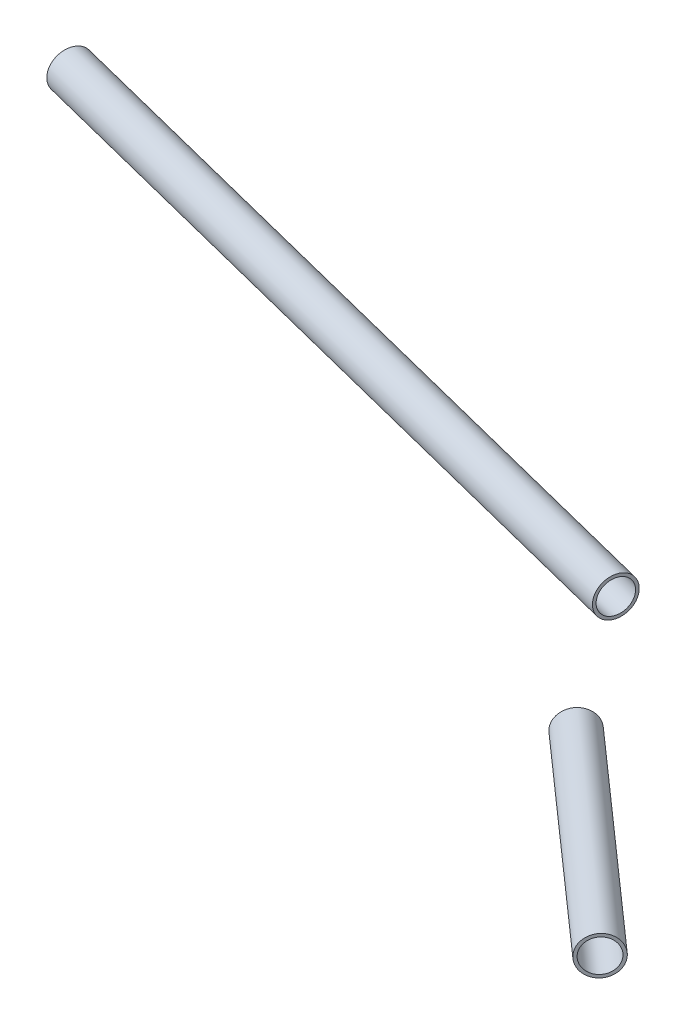
from build123d import *

# Parameters (mm, degrees)
SZKIC1_R                    = 6.349999996
DODANIE_WYCI_GNI_CIE1_DEPTH = 91.164431394
SZKIC2_R                    = 6.349999998
DODANIE_WYCI_GNI_CIE2_DEPTH = 247.228842592
SKORUPA1_T                  = -1
SKORUPA2_T                  = -1


with BuildPart() as part:
    # Szkic1 → Dodanie-wyciągnięcie1 (new body)
    with BuildSketch(Plane(origin=(100.119816365, 0, 88.569559312), x_dir=(-0.6625823992959091, 0, 0.7489890280526655), z_dir=(-0.7489890280526655, 0, -0.6625823992959091))):
        with Locations((423.248159606, 467.999999999)):
            Circle(SZKIC1_R)
    extrude(amount=DODANIE_WYCI_GNI_CIE1_DEPTH)

    # Skorupa2
    skorupa2_openings = [part.faces().sort_by_distance(p)[0] for p in [
        (-180.316964724, 467.999999999, 405.577787),
        (-248.598123587, 467.999999999, 345.173839317),
    ]]
    offset(amount=SKORUPA2_T, openings=skorupa2_openings, kind=Kind.INTERSECTION)


with BuildPart() as body_2:
    # Szkic2 → Dodanie-wyciągnięcie2 (new body)
    with BuildSketch(Plane(origin=(-192.244416892, 1e-09, -48.36049147), x_dir=(-0.2439567983035096, 0, 0.9697861004167365), z_dir=(-0.9697861004167366, 6.6607780708785495e-12, -0.24395679830350964))):
        with Locations((359.898466208, 467.999999999)):
            Circle(SZKIC2_R)
    extrude(amount=DODANIE_WYCI_GNI_CIE2_DEPTH)

    # Skorupa1
    skorupa1_openings = [body_2.faces().sort_by_distance(p)[0] for p in [
        (-280.044094419, 468.000000001, 300.664038621),
        (-519.803189587, 468.000000002, 240.350881734),
    ]]
    offset(amount=SKORUPA1_T, openings=skorupa1_openings, kind=Kind.INTERSECTION)


solid = Compound([part.part, body_2.part])
